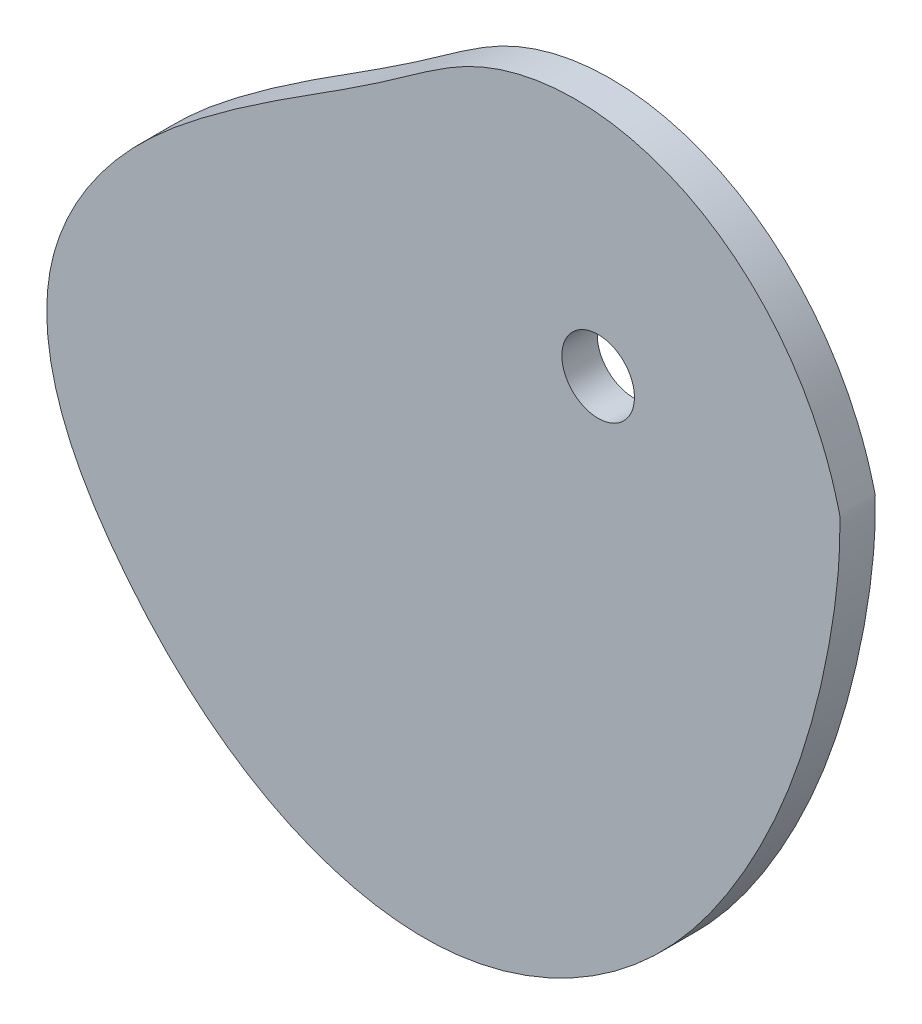
from build123d import *

# Parameters (mm, degrees)
SKETCH1_R           = 3.075
BOSS_EXTRUDE1_DEPTH = 1.5


with BuildPart() as part:
    # Sketch1 → Boss-Extrude1 (new, symmetric)
    with BuildSketch(Plane.XY):
        with BuildLine():
            add(Edge.make_bspline(
                [(20.469276515, 0), (20.453926982, 0.12032637), (20.37906939, 0.354674879), (20.296830063, 0.708499092), (20.201433403, 1.058274137), (20.104513169, 1.405451482), (20.003039964, 1.749648928), (19.897882185, 2.090972241), (19.788868962, 2.429397518), (19.676103633, 2.764935406), (19.559614296, 3.097587319), (19.439446847, 3.427357), (19.315640263, 3.754247363), (19.18823323, 4.078261244), (19.057262426, 4.399401123), (18.922763033, 4.717669117), (18.784768655, 5.033066908), (18.643311395, 5.345595684), (18.498421896, 5.655256084), (18.350129388, 5.962048143), (18.198461741, 6.265971239), (18.043445514, 6.567024042), (17.885106009, 6.865204466), (17.723467325, 7.160509621), (17.558552411, 7.452935769), (17.390383125, 7.742478283), (17.218980293, 8.029131604), (17.044363762, 8.312889204), (16.866552466, 8.593743551), (16.685564483, 8.871686073), (16.501417094, 9.146707128), (16.314126853, 9.418795975), (16.123709641, 9.687940747), (15.930180735, 9.954128423), (15.73355487, 10.21734481), (15.533846304, 10.477574522), (15.331068884, 10.734800958), (15.125236108, 10.989006292), (14.916361195, 11.240171456), (14.704457148, 11.48827613), (14.48953682, 11.733298735), (14.271612982, 11.975216425), (14.050698387, 12.214005082), (13.826805837, 12.449639318), (13.599948249, 12.682092471), (13.37013872, 12.911336613), (13.137390595, 13.137342549), (12.901717528, 13.360079832), (12.66313355, 13.579516764), (12.42165313, 13.795620417), (12.177291245, 14.00835664), (11.930063436, 14.21769008), (11.679985874, 14.423584196), (11.427075422, 14.626001285), (11.171349697, 14.824902501), (10.912827125, 15.020247881), (10.651527006, 15.211996372), (10.387469571, 15.400105862), (10.120676038, 15.584533205), (9.851168668, 15.765234263), (9.578970821, 15.942163933), (9.30410701, 16.115276188), (9.026602952, 16.284524115), (8.746485624, 16.449859953), (8.463783305, 16.611235142), (8.178525632, 16.768600359), (7.890743643, 16.921905569), (7.600469825, 17.071100071), (7.307738154, 17.216132546), (7.012584144, 17.356951111), (6.71504488, 17.493503366), (6.415159063, 17.625736452), (6.112967045, 17.753597106), (5.808510864, 17.877031712), (5.501834279, 17.995986365), (5.192982801, 18.110406928), (4.882003722, 18.22023909), (4.568946147, 18.32542843), (4.253861014, 18.425920478), (3.936801123, 18.521660778), (3.617821156, 18.612594954), (3.296977698, 18.698668773), (2.974329252, 18.779828214), (2.649936258, 18.856019533), (2.323861105, 18.927189329), (1.996168144, 18.993284617), (1.666923695, 19.054252892), (1.336196056, 19.110042202), (1.004055505, 19.160601215), (0.670574308, 19.205879292), (0.335826712, 19.245826554), (-0.000111049, 19.280393959), (-0.337160764, 19.309533366), (-0.675242249, 19.33319761), (-1.014273357, 19.351340575), (-1.354169986, 19.36391726), (-1.694846096, 19.370883857), (-2.036213723, 19.372197815), (-2.378182996, 19.367817918), (-2.720662158, 19.357704349), (-3.06355759, 19.341818766), (-3.406773832, 19.320124369), (-3.750213613, 19.29258597), (-4.093777879, 19.259170061), (-4.437365826, 19.219844885), (-4.780874932, 19.174580501), (-5.124200991, 19.123348854), (-5.467238158, 19.066123837), (-5.809878982, 19.002881361), (-6.152014452, 18.933599416), (-6.493534041, 18.858258136), (-6.834325754, 18.776839862), (-7.174276174, 18.689329199), (-7.513270515, 18.595713085), (-7.851192674, 18.49598084), (-8.187925289, 18.39012423), (-8.52334979, 18.278137522), (-8.857346463, 18.160017536), (-9.18979451, 18.035763705), (-9.520572102, 17.905378106), (-9.849556485, 17.76886559), (-10.176623887, 17.626233534), (-10.501650192, 17.477492989), (-10.824508724, 17.322654615), (-11.145080224, 17.161743427), (-11.463230747, 16.994735948), (-11.779050897, 16.821987195), (-12.092717082, 16.643916451), (-12.40442328, 16.460901436), (-12.714391967, 16.273307346), (-13.022869092, 16.08147821), (-13.330124311, 15.885737879), (-13.636449754, 15.686388462), (-13.942159146, 15.48370949), (-14.247586785, 15.277956924), (-14.553086511, 15.069362251), (-14.859030639, 14.858131599), (-15.165808852, 14.64444489), (-15.473827068, 14.428455032), (-15.783506277, 14.210287148), (-16.095281345, 13.990037832), (-16.40959979, 13.767774461), (-16.72692054, 13.54353453), (-17.047712658, 13.317325034), (-17.372454053, 13.089121892), (-17.701630161, 12.858869404), (-18.035732622, 12.62647976), (-18.375257928, 12.391832591), (-18.720706063, 12.15477456), (-19.072579127, 11.915119006), (-19.43137995, 11.672645633), (-19.797610697, 11.427100253), (-20.171771452, 11.17819457), (-20.554358808, 10.925606023), (-20.94586444, 10.668977684), (-21.346773666, 10.407918194), (-21.757564012, 10.14200177), (-22.178703761, 9.870768248), (-22.6106505, 9.593723189), (-23.053849668, 9.310338029), (-23.508733094, 9.020050289), (-23.975717536, 8.722263829), (-24.455203223, 8.416349151), (-24.947572399, 8.101643764), (-25.453187868, 7.777452583), (-25.972391547, 7.443048392), (-26.505503025, 7.097672347), (-27.052818136, 6.74053453), (-27.614607536, 6.370814557), (-28.191115299, 5.98766223), (-28.782557525, 5.590198235), (-29.389120965, 5.1775149), (-30.01096166, 4.74867698), (-30.64820362, 4.302722541), (-31.300937436, 3.838663708), (-31.969219271, 3.355488182), (-32.653068482, 2.852157975), (-33.352355561, 2.327705554), (-34.066325533, 1.781561053), (-34.792156176, 1.21198818), (-35.526433511, 0.617909195), (-36.265587734, -0.001457622), (-37.006020345, -0.646671842), (-37.744112291, -1.318073183), (-38.476233993, -2.015780313), (-39.198754785, -2.739691012), (-39.908052424, -3.489482365), (-40.600522516, -4.264611377), (-41.272587879, -5.064315898), (-41.920707839, -5.8876159), (-42.541387444, -6.733315094), (-43.131186577, -7.600002901), (-43.686728957, -8.486056757), (-44.204711001, -9.389644786), (-44.681910487, -10.308728765), (-45.115195144, -11.241067557), (-45.501530481, -12.184220343), (-45.837989248, -13.135551967), (-46.121753439, -14.092231719), (-46.350171981, -15.051382919), (-46.520731563, -16.010470183), (-46.635259313, -16.966833368), (-46.695881182, -17.918707922), (-46.704758414, -18.864589252), (-46.664077675, -19.803116927), (-46.576039325, -20.733069832), (-46.442852564, -21.653366621), (-46.266728948, -22.563064411), (-46.04987654, -23.461357639), (-45.794494099, -24.347576614), (-45.502765451, -25.221185937), (-45.176853985, -26.081782762), (-44.818897277, -26.929094921), (-44.431001821, -27.762978927), (-44.015237852, -28.583417844), (-43.57363427, -29.390519034), (-43.108173634, -30.184511764), (-42.620787267, -30.965744674), (-42.113350378, -31.734683158), (-41.587677508, -32.491906358), (-41.045517213, -33.238104962), (-40.488554103, -33.974069902), (-39.918413965, -34.700676565), (-39.33481729, -35.417341816), (-38.737534614, -36.123431266), (-38.126368953, -36.818284488), (-37.501156774, -37.501216811), (-36.861768424, -38.171521432), (-36.208109378, -38.828470556), (-35.54012122, -39.471316853), (-34.857782619, -40.099294871), (-34.161110261, -40.711622507), (-33.450159719, -41.307502509), (-32.725026287, -41.886124006), (-31.985845748, -42.446664075), (-31.232795105, -42.98828933), (-30.466093242, -43.510157547), (-29.686001549, -44.011419305), (-28.892824481, -44.491219662), (-28.08691006, -44.948699845), (-27.268650333, -45.382998964), (-26.438481761, -45.793255749), (-25.596885557, -46.178610297), (-24.744387965, -46.538205845), (-23.881560483, -46.871190547), (-23.009020024, -47.176719273), (-22.127429019, -47.45395541), (-21.237495463, -47.702072683), (-20.339972901, -47.920256977), (-19.435660354, -48.10770816), (-18.525402181, -48.263641942), (-17.610087896, -48.387291641), (-16.690651874, -48.477910274), (-15.768073177, -48.534771472), (-14.84337466, -48.55717479), (-13.917624463, -48.544434556), (-12.991941631, -48.495930985), (-12.067628664, -48.41094298), (-11.146068248, -48.290046351), (-10.228680944, -48.134143741), (-9.316882792, -47.944122816), (-8.412028473, -47.72093942), (-7.515412754, -47.465590968), (-6.62826823, -47.179120315), (-5.751764231, -46.862611411), (-4.88700552, -46.517187103), (-4.03503117, -46.144006323), (-3.196813506, -45.744261393), (-2.373257143, -45.319175263), (-1.565198119, -44.86999873), (-0.773403127, -44.398007635), (0.001431168, -43.904500034), (0.758678706, -43.390793354), (1.497784521, -42.858221534), (2.218265124, -42.308132156), (2.919708798, -41.74188356), (3.601775788, -41.160841961), (4.2641984, -40.566378558), (4.906780999, -39.959866645), (5.529399907, -39.342678725), (6.132003211, -38.716183626), (6.714610467, -38.081743631), (7.277312313, -37.440711615), (7.82026998, -36.794428197), (8.343714715, -36.144218914), (8.847947092, -35.491391398), (9.333336294, -34.837232621), (9.800319062, -34.183006019), (10.24939942, -33.529949158), (10.681145161, -32.879269558), (11.096195715, -32.232147378), (11.49523197, -31.589707036), (11.879149859, -30.952992781), (12.248517048, -30.322552069), (12.603694342, -29.698556098), (12.945153788, -29.0811272), (13.273344314, -28.470359529), (13.588713491, -27.866335339), (13.891701075, -27.269121707), (14.182740239, -26.678771864), (14.462256803, -26.095325337), (14.730669009, -25.518808409), (14.988387177, -24.949234509), (15.2358134, -24.386604625), (15.473341258, -23.830907716), (15.701355534, -23.282121139), (15.920231962, -22.740211075), (16.130336972, -22.205132959), (16.332027463, -21.676831916), (16.525650586, -21.155243203), (16.711543541, -20.640292652), (16.890033391, -20.131897115), (17.061436892, -19.629964916), (17.226060335, -19.134396296), (17.384199405, -18.645083873), (17.536139055, -18.161913089), (17.682153396, -17.684762669), (17.822505599, -17.213505075), (17.957447815, -16.748006957), (18.087221108, -16.288129613), (18.212055405, -15.833729436), (18.332169455, -15.384658369), (18.447770812, -14.940764355), (18.559055824, -14.501891782), (18.666209639, -14.067881928), (18.769406229, -13.638573405), (18.868808423, -13.213802595), (18.964567955, -12.793404083), (19.056825528, -12.37721109), (19.14571089, -11.965055896), (19.231342923, -11.556770257), (19.313829749, -11.152185827), (19.393268841, -10.751134561), (19.469747157, -10.353449118), (19.543341277, -9.95896326), (19.614117561, -9.567512236), (19.682132311, -9.178933172), (19.747431952, -8.793065437), (19.810053221, -8.409751015), (19.870023364, -8.028834861), (19.927360353, -7.650165254), (19.982073105, -7.273594135), (20.034161718, -6.898977439), (20.083617711, -6.526175422), (20.130424277, -6.15505297), (20.174556549, -5.785479904), (20.215981868, -5.417331275), (20.254660065, -5.050487643), (20.290543747, -4.684835353), (20.323578606, -4.320266795), (20.353703685, -3.956680655), (20.380851823, -3.593982143), (20.404949486, -3.232083278), (20.425918912, -2.87090287), (20.443671673, -2.510367615), (20.458134208, -2.150408957), (20.469154396, -1.790975662), (20.476850973, -1.431987855), (20.480314085, -1.073508931), (20.482447125, -0.715105964), (20.47192834, -0.358233383), (20.484273463, -0.11756243), (20.469276515, 0)],
                knots=[0, 0, 0, 0, 0.001764203, 0.003519492, 0.005266096, 0.007004244, 0.008734164, 0.010456082, 0.01217022, 0.013876802, 0.015576046, 0.017268173, 0.018953398, 0.020631935, 0.022303998, 0.023969797, 0.025629542, 0.027283438, 0.02893169, 0.030574501, 0.032212071, 0.033844598, 0.035472279, 0.037095307, 0.038713875, 0.04032817, 0.041938381, 0.043544692, 0.045147285, 0.046746342, 0.048342038, 0.04993455, 0.05152405, 0.053110709, 0.054694695, 0.056276173, 0.057855307, 0.059432256, 0.061007179, 0.062580232, 0.064151567, 0.065721335, 0.067289683, 0.068856757, 0.070422701, 0.071987653, 0.073551752, 0.075115133, 0.076677929, 0.078240269, 0.079802281, 0.08136409, 0.082925818, 0.084487586, 0.08604951, 0.087611705, 0.089174283, 0.090737355, 0.092301027, 0.093865405, 0.09543059, 0.096996683, 0.09856378, 0.100131977, 0.101701366, 0.103272038, 0.10484408, 0.106417578, 0.107992614, 0.109569269, 0.111147622, 0.112727748, 0.114309722, 0.115893614, 0.117479494, 0.11906743, 0.120657485, 0.122249722, 0.123844203, 0.125440984, 0.127040123, 0.128641672, 0.130245685, 0.13185221, 0.133461296, 0.135072989, 0.136687331, 0.138304365, 0.139924131, 0.141546665, 0.143172005, 0.144800184, 0.146431233, 0.148065183, 0.149702063, 0.151341898, 0.152984714, 0.154630532, 0.156279374, 0.157931258, 0.159586203, 0.161244224, 0.162905335, 0.164569548, 0.166236874, 0.167907321, 0.169580897, 0.171257607, 0.172937454, 0.174620442, 0.176306572, 0.177995841, 0.179688248, 0.181383788, 0.183082456, 0.184784246, 0.186489147, 0.188197151, 0.189908245, 0.191622417, 0.193339652, 0.195059933, 0.196783244, 0.198509566, 0.200238878, 0.201971181, 0.203706635, 0.205445504, 0.2071881, 0.208934793, 0.210686019, 0.212442285, 0.214204179, 0.215972379, 0.217747655, 0.219530879, 0.221323028, 0.223125194, 0.224938584, 0.226764524, 0.228604465, 0.230459983, 0.232332781, 0.234224685, 0.236137652, 0.238073757, 0.2400352, 0.242024293, 0.244043462, 0.246095238, 0.248182252, 0.250307226, 0.252472967, 0.254682362, 0.256938364, 0.259243991, 0.261602312, 0.264016447, 0.266489554, 0.269024826, 0.271625481, 0.274294763, 0.277035933, 0.279852264, 0.282747038, 0.285723547, 0.288785083, 0.291934943, 0.295176421, 0.298512813, 0.30194741, 0.305483503, 0.309124377, 0.312873317, 0.316733603, 0.320708513, 0.324801324, 0.329015309, 0.333351662, 0.33780314, 0.342360129, 0.347012767, 0.351751024, 0.35656476, 0.361443788, 0.366377916, 0.371356998, 0.376370977, 0.381409928, 0.386464106, 0.391523993, 0.396580347, 0.401624264, 0.406647238, 0.411641236, 0.416598779, 0.421513038, 0.426377942, 0.431188305, 0.435939966, 0.440631828, 0.445270717, 0.449864684, 0.454421044, 0.458946377, 0.463446541, 0.467926691, 0.472391308, 0.476844238, 0.481288728, 0.48572748, 0.490162693, 0.494596121, 0.499029126, 0.50346273, 0.507897674, 0.512334472, 0.516773466, 0.521214882, 0.525658883, 0.530105625, 0.534555313, 0.539008153, 0.543464074, 0.5479229, 0.552384417, 0.556848379, 0.561314515, 0.565782528, 0.570252105, 0.57472292, 0.579194639, 0.583666924, 0.588139439, 0.592611855, 0.597083853, 0.601555132, 0.606025412, 0.610494439, 0.614961992, 0.619427887, 0.623891985, 0.628354194, 0.632814475, 0.637272853, 0.641729416, 0.646184326, 0.650637823, 0.655090233, 0.659541971, 0.663993554, 0.668445597, 0.672898832, 0.677354104, 0.681812384, 0.68627477, 0.690742499, 0.695216754, 0.699697325, 0.704183213, 0.708673274, 0.713166232, 0.71766069, 0.722155137, 0.726647962, 0.731137456, 0.735621826, 0.7400992, 0.744567632, 0.749025113, 0.753469575, 0.757898896, 0.762310907, 0.766703399, 0.771074124, 0.775420805, 0.779741136, 0.784032793, 0.788293433, 0.792520702, 0.796712241, 0.800865688, 0.804978687, 0.809048891, 0.813073968, 0.817051612, 0.820979544, 0.824855525, 0.82867736, 0.832442913, 0.836150111, 0.839796963, 0.843381676, 0.84690413, 0.850365453, 0.853766802, 0.857109335, 0.860394205, 0.863622561, 0.866795554, 0.86991433, 0.872980033, 0.875993807, 0.878956793, 0.881870128, 0.88473495, 0.887552392, 0.890323587, 0.893049665, 0.895731754, 0.898370977, 0.900968457, 0.903525314, 0.906042661, 0.908521612, 0.910963275, 0.913368751, 0.915739141, 0.918075538, 0.920379029, 0.922650695, 0.924891611, 0.927102843, 0.929285451, 0.931440483, 0.93356898, 0.935671971, 0.937750475, 0.939805498, 0.941838034, 0.943849063, 0.945839551, 0.947810449, 0.949762689, 0.95169719, 0.953614851, 0.955516554, 0.957403159, 0.959275508, 0.961134423, 0.962980703, 0.964815124, 0.966638443, 0.96845139, 0.970254675, 0.972048981, 0.973834969, 0.975613274, 0.977384508, 0.979149256, 0.980908081, 0.982661518, 0.984410078, 0.98615425, 0.987894493, 0.989631248, 0.991364926, 0.993095918, 0.994824589, 0.996551283, 0.998276321, 1, 1, 1, 1], degree=3))
        make_face()
        Circle(SKETCH1_R, mode=Mode.SUBTRACT)
    extrude(amount=BOSS_EXTRUDE1_DEPTH, both=True)


solid = part.part
